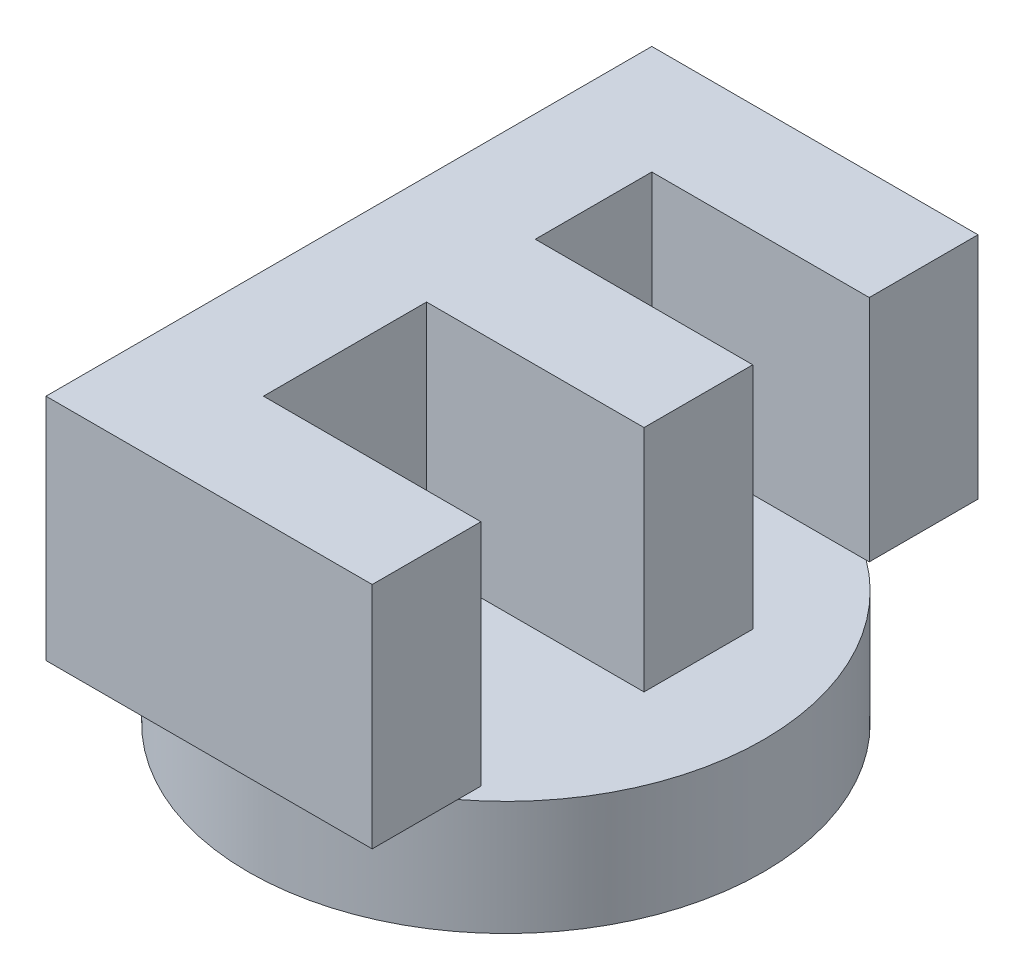
from build123d import *

# Parameters (mm, degrees)
SKETCH1_R           = 22.5
BOSS_EXTRUDE1_DEPTH = 10
BOSS_EXTRUDE2_DEPTH = 20
SKETCH3_R           = 16.5
CUT_EXTRUDE2_DEPTH  = 5


with BuildPart() as part:
    # Sketch1 → Boss-Extrude1 (new body)
    with BuildSketch(Plane(origin=(0, 0, 0), x_dir=(1, 0, 0), z_dir=(0, 1, 0))):
        with Locations(Location((0, 0, 0), (0, 0, 270))):
            Circle(SKETCH1_R)
    extrude(amount=BOSS_EXTRUDE1_DEPTH)

    # Sketch2 → Boss-Extrude2 (add)
    with BuildSketch(Plane(origin=(0, 10, 0), x_dir=(1, 0, 0), z_dir=(0, 1, 0))):
        Polygon((-14.828901743, 27.574589589), (13.664688, 27.574589589), (13.664688, 18.076726341), (-5.331038496, 18.076726341), (-5.331038496, 7.90044429), (13.664688, 7.90044429), (13.664688, -1.597418958), (-5.331038496, -1.597418958), (-5.331038496, -15.84421383), (13.664688, -15.84421383), (13.664688, -25.342077078), (-14.828901743, -25.342077078), align=None)
    extrude(amount=BOSS_EXTRUDE2_DEPTH)

    # Sketch3 → Cut-Extrude2 (cut)
    with BuildSketch(Plane.XZ):
        with BuildLine():
            ThreePointArc((-14.551420086, 2.778571429), (0, 11.5), (14.551420086, 2.778571429))
            Line((14.551420086, 2.778571429), (4.83856504, 20.948467447))
            ThreePointArc((4.83856504, 20.948467447), (0, 21.5), (-4.83856504, 20.948467447))
            Line((-4.83856504, 20.948467447), (-14.551420086, 2.778571429))
        make_face()
        with Locations((0, -5)):
            Circle(SKETCH3_R)
    extrude(amount=-CUT_EXTRUDE2_DEPTH, mode=Mode.SUBTRACT)


solid = part.part
